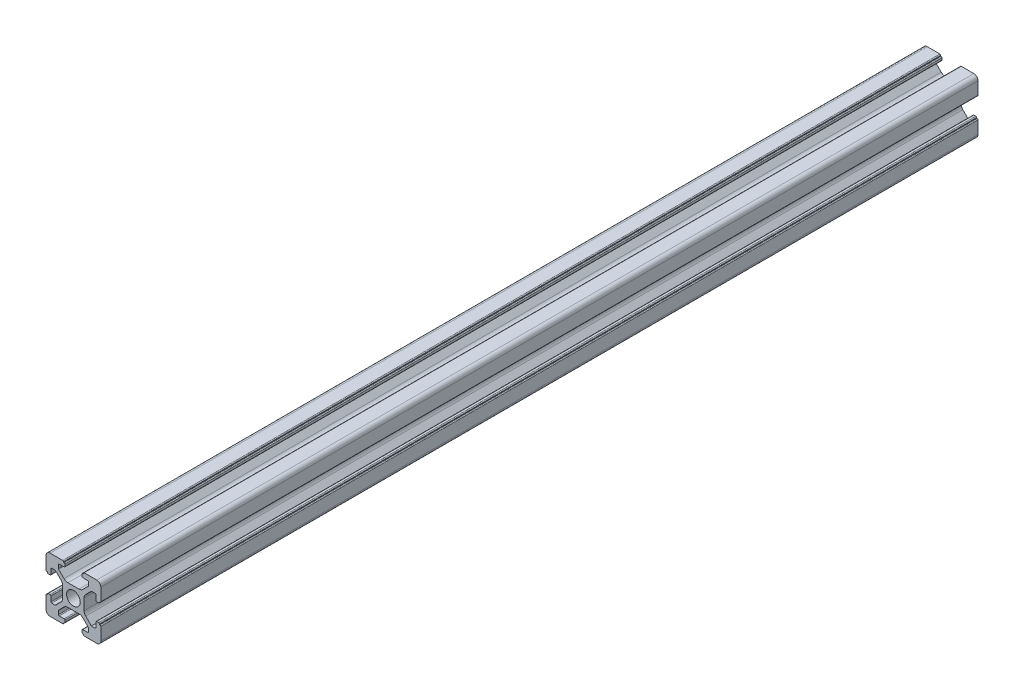
from build123d import *

# Parameters (mm, degrees)
SKETCH_1_R          = 2.5
BOSS_EXTRUDE1_DEPTH = 320


with BuildPart() as part:
    # 草图1 → Boss-Extrude1 (new body)
    with BuildSketch(Plane.XY):
        with BuildLine():
            Line((3.9, 0), (3.9, -2.010912703))
            ThreePointArc((3.9, -2.010912703), (4.052240935, -2.776279568), (4.485786438, -3.425126266))
            Line((4.485786438, -3.425126266), (6.560660172, -5.5))
            Line((6.560660172, -5.5), (7.9, -5.5))
            ThreePointArc((7.9, -5.5), (8.112132034, -5.412132034), (8.2, -5.2))
            Line((8.2, -5.2), (8.2, -3.4))
            ThreePointArc((8.2, -3.4), (8.287867966, -3.187867966), (8.5, -3.1))
            Line((8.5, -3.1), (9.2, -3.1))
            ThreePointArc((9.2, -3.1), (9.412132034, -3.187867966), (9.5, -3.4))
            Line((9.5, -3.4), (9.5, -3.6))
            Line((9.5, -3.6), (9.7, -3.6))
            ThreePointArc((9.7, -3.6), (9.912132034, -3.687867966), (10, -3.9))
            Line((10, -3.9), (10, -8.5))
            ThreePointArc((10, -8.5), (9.560660172, -9.560660172), (8.5, -10))
            Line((8.5, -10), (3.9, -10))
            ThreePointArc((3.9, -10), (3.687867966, -9.912132034), (3.6, -9.7))
            ThreePointArc((3.6, -9.7), (3.541421356, -9.558578644), (3.4, -9.5))
            ThreePointArc((3.4, -9.5), (3.187867966, -9.412132034), (3.1, -9.2))
            Line((3.1, -9.2), (3.1, -8.5))
            ThreePointArc((3.1, -8.5), (3.187867966, -8.287867966), (3.4, -8.2))
            Line((3.4, -8.2), (5.2, -8.2))
            ThreePointArc((5.2, -8.2), (5.412132034, -8.112132034), (5.5, -7.9))
            Line((5.5, -7.9), (5.5, -6.68492424))
            ThreePointArc((5.5, -6.68492424), (5.47716386, -6.570119211), (5.412132034, -6.472792206))
            Line((5.412132034, -6.472792206), (3.425126266, -4.485786438))
            ThreePointArc((3.425126266, -4.485786438), (2.776279568, -4.052240935), (2.010912703, -3.9))
            Line((2.010912703, -3.9), (0, -3.9))
            Line((0, -3.9), (-2.010912703, -3.9))
            ThreePointArc((-2.010912703, -3.9), (-2.776279568, -4.052240935), (-3.425126266, -4.485786438))
            Line((-3.425126266, -4.485786438), (-5.412132034, -6.472792206))
            ThreePointArc((-5.412132034, -6.472792206), (-5.47716386, -6.570119211), (-5.5, -6.68492424))
            Line((-5.5, -6.68492424), (-5.5, -7.9))
            ThreePointArc((-5.5, -7.9), (-5.412132034, -8.112132034), (-5.2, -8.2))
            Line((-5.2, -8.2), (-3.4, -8.2))
            ThreePointArc((-3.4, -8.2), (-3.187867966, -8.287867966), (-3.1, -8.5))
            Line((-3.1, -8.5), (-3.1, -9.2))
            ThreePointArc((-3.1, -9.2), (-3.187867966, -9.412132034), (-3.4, -9.5))
            ThreePointArc((-3.4, -9.5), (-3.541421356, -9.558578644), (-3.6, -9.7))
            ThreePointArc((-3.6, -9.7), (-3.687867966, -9.912132034), (-3.9, -10))
            Line((-3.9, -10), (-8.5, -10))
            ThreePointArc((-8.5, -10), (-9.560660172, -9.560660172), (-10, -8.5))
            Line((-10, -8.5), (-10, -3.9))
            ThreePointArc((-10, -3.9), (-9.912132034, -3.687867966), (-9.7, -3.6))
            Line((-9.7, -3.6), (-9.5, -3.6))
            Line((-9.5, -3.6), (-9.5, -3.4))
            ThreePointArc((-9.5, -3.4), (-9.412132034, -3.187867966), (-9.2, -3.1))
            Line((-9.2, -3.1), (-8.5, -3.1))
            ThreePointArc((-8.5, -3.1), (-8.287867965, -3.187867966), (-8.2, -3.4))
            Line((-8.2, -3.4), (-8.2, -5.2))
            ThreePointArc((-8.2, -5.2), (-8.112132034, -5.412132034), (-7.9, -5.5))
            Line((-7.9, -5.5), (-6.68492424, -5.5))
            ThreePointArc((-6.68492424, -5.5), (-6.570119211, -5.47716386), (-6.472792206, -5.412132034))
            Line((-6.472792206, -5.412132034), (-4.485786438, -3.425126266))
            ThreePointArc((-4.485786438, -3.425126266), (-4.052240935, -2.776279568), (-3.9, -2.010912703))
            Line((-3.9, -2.010912703), (-3.9, 0))
            Line((-3.9, 0), (-3.9, 2.010912703))
            ThreePointArc((-3.9, 2.010912703), (-4.052240935, 2.776279568), (-4.485786438, 3.425126266))
            Line((-4.485786438, 3.425126266), (-6.472792206, 5.412132034))
            ThreePointArc((-6.472792206, 5.412132034), (-6.570119211, 5.47716386), (-6.68492424, 5.5))
            Line((-6.68492424, 5.5), (-7.9, 5.5))
            ThreePointArc((-7.9, 5.5), (-8.112132034, 5.412132034), (-8.2, 5.2))
            Line((-8.2, 5.2), (-8.2, 3.4))
            ThreePointArc((-8.2, 3.4), (-8.287867965, 3.187867966), (-8.5, 3.1))
            Line((-8.5, 3.1), (-9.2, 3.1))
            ThreePointArc((-9.2, 3.1), (-9.412132034, 3.187867966), (-9.5, 3.4))
            Line((-9.5, 3.4), (-9.5, 3.6))
            Line((-9.5, 3.6), (-9.7, 3.6))
            ThreePointArc((-9.7, 3.6), (-9.912132034, 3.687867966), (-10, 3.9))
            Line((-10, 3.9), (-10, 8.5))
            ThreePointArc((-10, 8.5), (-9.560660172, 9.560660172), (-8.5, 10))
            Line((-8.5, 10), (-3.9, 10))
            ThreePointArc((-3.9, 10), (-3.687867966, 9.912132034), (-3.6, 9.7))
            Line((-3.6, 9.7), (-3.6, 9.5))
            Line((-3.6, 9.5), (-3.4, 9.5))
            ThreePointArc((-3.4, 9.5), (-3.187867966, 9.412132034), (-3.1, 9.2))
            Line((-3.1, 9.2), (-3.1, 8.5))
            ThreePointArc((-3.1, 8.5), (-3.187867966, 8.287867966), (-3.4, 8.2))
            Line((-3.4, 8.2), (-5.2, 8.2))
            ThreePointArc((-5.2, 8.2), (-5.412132034, 8.112132034), (-5.5, 7.9))
            Line((-5.5, 7.9), (-5.5, 6.68492424))
            ThreePointArc((-5.5, 6.68492424), (-5.47716386, 6.570119211), (-5.412132034, 6.472792206))
            Line((-5.412132034, 6.472792206), (-3.425126266, 4.485786438))
            ThreePointArc((-3.425126266, 4.485786438), (-2.776279568, 4.052240935), (-2.010912703, 3.9))
            Line((-2.010912703, 3.9), (0, 3.9))
            Line((0, 3.9), (2.010912703, 3.9))
            ThreePointArc((2.010912703, 3.9), (2.776279568, 4.052240935), (3.425126266, 4.485786438))
            Line((3.425126266, 4.485786438), (5.412132034, 6.472792206))
            ThreePointArc((5.412132034, 6.472792206), (5.47716386, 6.570119211), (5.5, 6.68492424))
            Line((5.5, 6.68492424), (5.5, 7.9))
            ThreePointArc((5.5, 7.9), (5.412132034, 8.112132034), (5.2, 8.2))
            Line((5.2, 8.2), (3.4, 8.2))
            ThreePointArc((3.4, 8.2), (3.187867966, 8.287867966), (3.1, 8.5))
            Line((3.1, 8.5), (3.1, 9.2))
            ThreePointArc((3.1, 9.2), (3.187867966, 9.412132034), (3.4, 9.5))
            Line((3.4, 9.5), (3.6, 9.5))
            Line((3.6, 9.5), (3.6, 9.7))
            ThreePointArc((3.6, 9.7), (3.687867966, 9.912132034), (3.9, 10))
            Line((3.9, 10), (8.5, 10))
            ThreePointArc((8.5, 10), (9.560660172, 9.560660172), (10, 8.5))
            Line((10, 8.5), (10, 3.9))
            ThreePointArc((10, 3.9), (9.912132034, 3.687867966), (9.7, 3.6))
            Line((9.7, 3.6), (9.5, 3.6))
            Line((9.5, 3.6), (9.5, 3.4))
            ThreePointArc((9.5, 3.4), (9.412132034, 3.187867966), (9.2, 3.1))
            Line((9.2, 3.1), (8.5, 3.1))
            ThreePointArc((8.5, 3.1), (8.287867966, 3.187867966), (8.2, 3.4))
            Line((8.2, 3.4), (8.2, 5.2))
            ThreePointArc((8.2, 5.2), (8.112132034, 5.412132034), (7.9, 5.5))
            Line((7.9, 5.5), (6.68492424, 5.5))
            ThreePointArc((6.68492424, 5.5), (6.570119211, 5.47716386), (6.472792206, 5.412132034))
            Line((6.472792206, 5.412132034), (4.485786438, 3.425126266))
            ThreePointArc((4.485786438, 3.425126266), (4.052240935, 2.776279568), (3.9, 2.010912703))
            Line((3.9, 2.010912703), (3.9, 0))
        make_face()
        Circle(SKETCH_1_R, mode=Mode.SUBTRACT)
    extrude(amount=BOSS_EXTRUDE1_DEPTH)


solid = part.part
